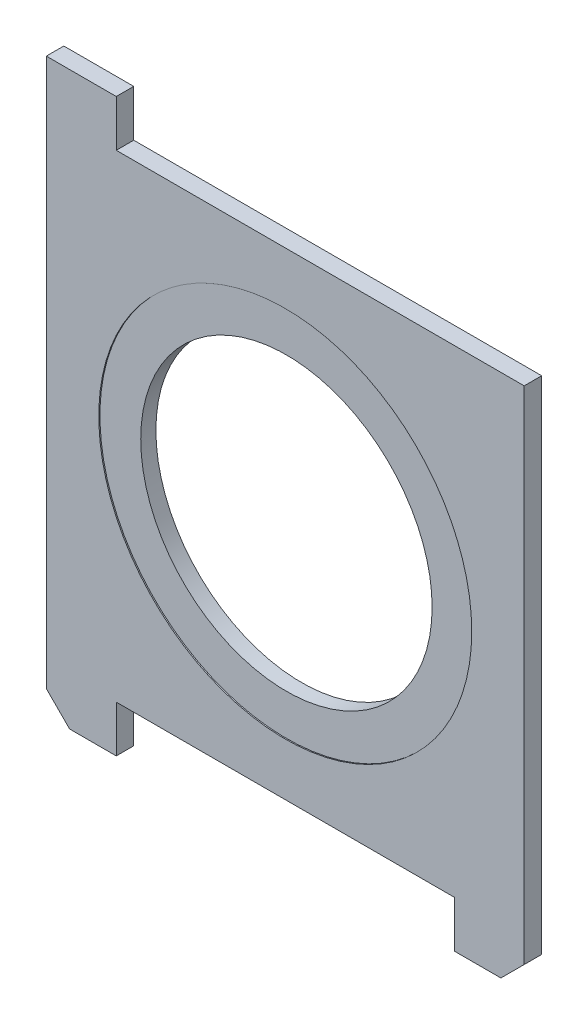
from build123d import *

# Parameters (mm, degrees)
ESQUISSE1_W             = 41
ESQUISSE1_H             = 41
BOSS_EXTRU_1_DEPTH      = 1.5
ESQUISSE2_W             = 6
ESQUISSE2_H             = 4
BOSS_EXTRU_2_DEPTH      = 1.5
ESQUISSE3_R             = 12.5
ENL_V_MAT_EXTRU_1_DEPTH = 2.5
ESQUISSE4_R             = 16
ENL_V_MAT_EXTRU_2_DEPTH = 0.1
ESQUISSE5_R             = 16
ENL_V_MAT_EXTRU_3_DEPTH = 0.1
CHANFREIN1_SIZE         = 2
CHANFREIN2_SIZE         = 2


with BuildPart() as part:
    # Esquisse1 → Boss.-Extru.1 (new body)
    with BuildSketch(Plane.XY):
        Rectangle(ESQUISSE1_W, ESQUISSE1_H)
    extrude(amount=BOSS_EXTRU_1_DEPTH)

    # Esquisse2 → Boss.-Extru.2 (add)
    with BuildSketch(Plane(origin=(0, 0, 0), x_dir=(-1, 0, 0), z_dir=(0, 0, -1))):
        with Locations((17.5, 22.5)):
            Rectangle(ESQUISSE2_W, ESQUISSE2_H)
        with Locations((-17.5, -22.5)):
            Rectangle(ESQUISSE2_W, ESQUISSE2_H)
        with Locations((17.5, -22.5)):
            Rectangle(ESQUISSE2_W, ESQUISSE2_H)
    extrude(amount=-BOSS_EXTRU_2_DEPTH)

    # Esquisse3 → Enlèv. mat.-Extru.1 (cut, through all)
    with BuildSketch(Plane(origin=(0, 0, 0), x_dir=(-1, 0, 0), z_dir=(0, 0, -1))):
        Circle(ESQUISSE3_R)
    extrude(amount=-ENL_V_MAT_EXTRU_1_DEPTH, mode=Mode.SUBTRACT)

    # Esquisse4 → Enlèv. mat.-Extru.2 (cut)
    with BuildSketch(Plane(origin=(0, 0, 0), x_dir=(-1, 0, 0), z_dir=(0, 0, -1))):
        Circle(ESQUISSE4_R)
    extrude(amount=-ENL_V_MAT_EXTRU_2_DEPTH, mode=Mode.SUBTRACT)

    # Esquisse5 → Enlèv. mat.-Extru.3 (cut)
    with BuildSketch(Plane.XY.offset(1.5)):
        Circle(ESQUISSE5_R)
    extrude(amount=-ENL_V_MAT_EXTRU_3_DEPTH, mode=Mode.SUBTRACT)

    # Chanfrein1
    chanfrein1_edges = [part.edges().sort_by_distance(p)[0] for p in [
        (-20.5, -24.5, 0.75),
    ]]
    chamfer(chanfrein1_edges, length=CHANFREIN1_SIZE)

    # Chanfrein2
    chanfrein2_edges = [part.edges().sort_by_distance(p)[0] for p in [
        (20.5, -24.5, 0.75),
    ]]
    chamfer(chanfrein2_edges, length=CHANFREIN2_SIZE)


solid = part.part
